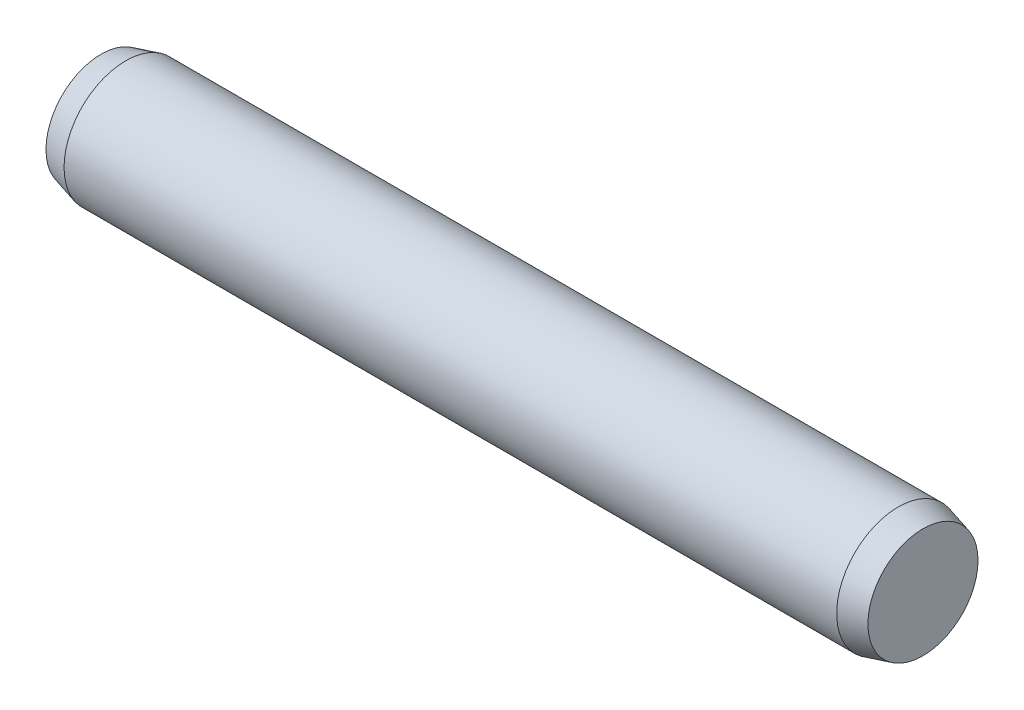
from build123d import *

# Parameters (mm, degrees)
SKETCH2_R           = 3
EXTRUDE1_DEPTH      = 18.8
EXTRUDE1_DEPTH_BACK = 18.8
SKETCH3_R           = 3
EXTRUDE2_DEPTH      = 1.2
EXTRUDE2_TAPER      = 15
SKETCH4_R           = 3
EXTRUDE3_DEPTH      = 1.2
EXTRUDE3_TAPER      = 15


with BuildPart() as part:
    # Sketch2 → Extrude1 (new body, two sides)
    with BuildSketch(Plane(origin=(0, 0, 0), x_dir=(0, 0, -1), z_dir=(1, 0, 0))) as extrude1_sk:
        Circle(SKETCH2_R)
    extrude(amount=EXTRUDE1_DEPTH)
    extrude(extrude1_sk.sketch, amount=-EXTRUDE1_DEPTH_BACK)

    # Sketch3 → Extrude2 (add)
    with BuildSketch(Plane(origin=(18.8, 0, 0), x_dir=(0, 0, -1), z_dir=(1, 0, 0))):
        Circle(SKETCH3_R)
    extrude(amount=EXTRUDE2_DEPTH, taper=EXTRUDE2_TAPER)

    # Sketch4 → Extrude3 (add)
    with BuildSketch(Plane.ZY.offset(18.8)):
        Circle(SKETCH4_R)
    extrude(amount=EXTRUDE3_DEPTH, taper=EXTRUDE3_TAPER)


solid = part.part
